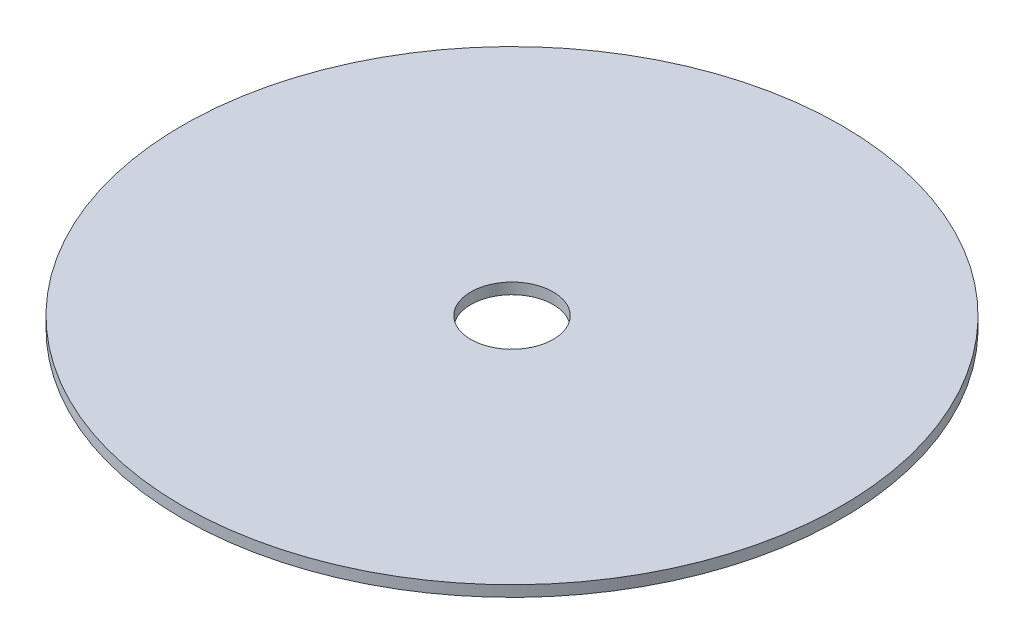
from build123d import *

# Parameters (mm, degrees)
ESQUISSE1_W      = 18
ESQUISSE1_H      = 18
EXTRUSION1_DEPTH = 18
ESQUISSE2_R      = 60
ESQUISSE2_R_2    = 7.5
EXTRUSION2_DEPTH = 2


with BuildPart() as part:
    # Esquisse1 → Extrusion1 (new body)
    with BuildSketch(Plane(origin=(0, 0, 0), x_dir=(1, 0, 0), z_dir=(0, 1, 0))):
        with Locations((9, 9)):
            Rectangle(ESQUISSE1_W, ESQUISSE1_H)
    extrude(amount=EXTRUSION1_DEPTH)

    # Esquisse2 → Extrusion2 (add)
    with BuildSketch(Plane(origin=(0, 18, 0), x_dir=(1, 0, 0), z_dir=(0, 1, 0))):
        with Locations((9, -31.5)):
            Circle(ESQUISSE2_R)
        with Locations((9, -31.5)):
            Circle(ESQUISSE2_R_2, mode=Mode.SUBTRACT)
    extrude(amount=EXTRUSION2_DEPTH)


solid = part.part
